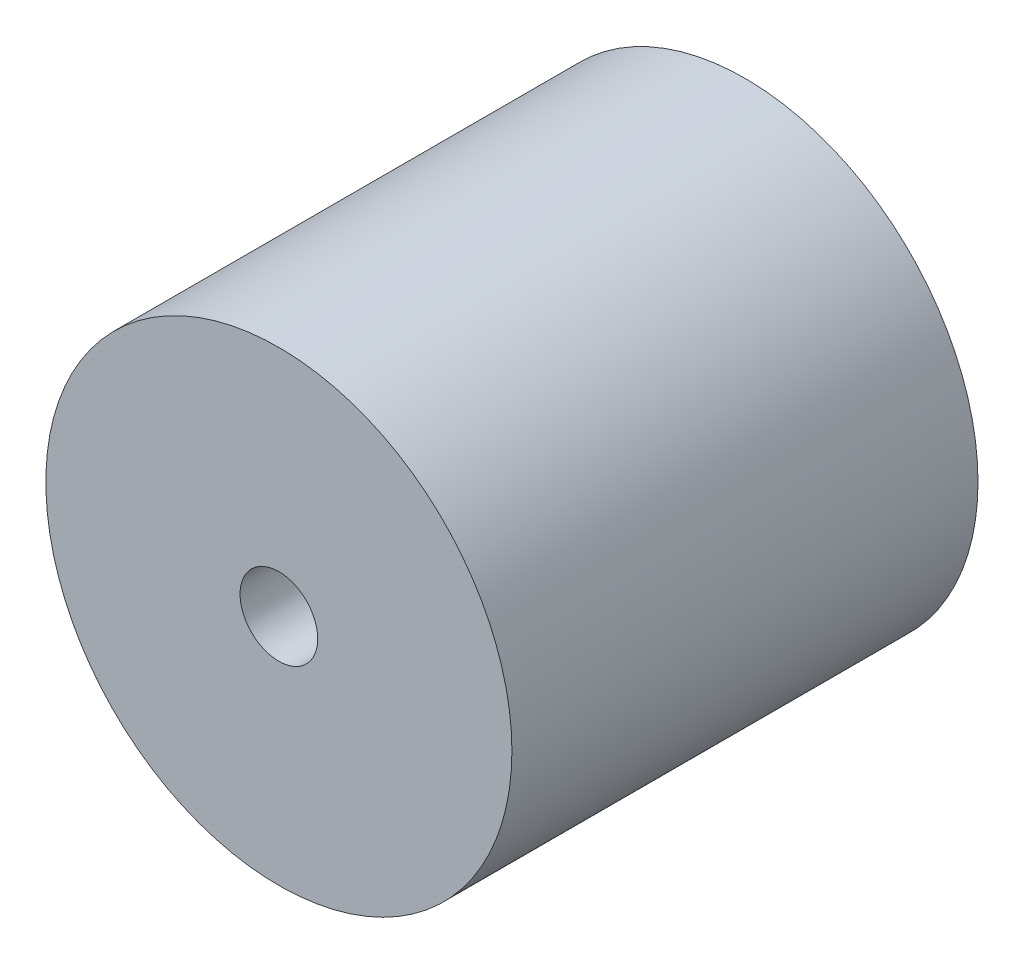
from build123d import *

# Parameters (mm, degrees)
ESQUISSE1_R             = 30
BOSS_EXTRU_1_DEPTH      = 60
ESQUISSE2_R             = 5
ENL_V_MAT_EXTRU_1_DEPTH = 60


with BuildPart() as part:
    # Esquisse1 → Boss.-Extru.1 (new body)
    with BuildSketch(Plane.XY):
        Circle(ESQUISSE1_R)
    extrude(amount=BOSS_EXTRU_1_DEPTH)

    # Esquisse2 → Enlèv. mat.-Extru.1 (cut)
    with BuildSketch(Plane.XY.offset(60)):
        Circle(ESQUISSE2_R)
    extrude(amount=-ENL_V_MAT_EXTRU_1_DEPTH, mode=Mode.SUBTRACT)


solid = part.part
